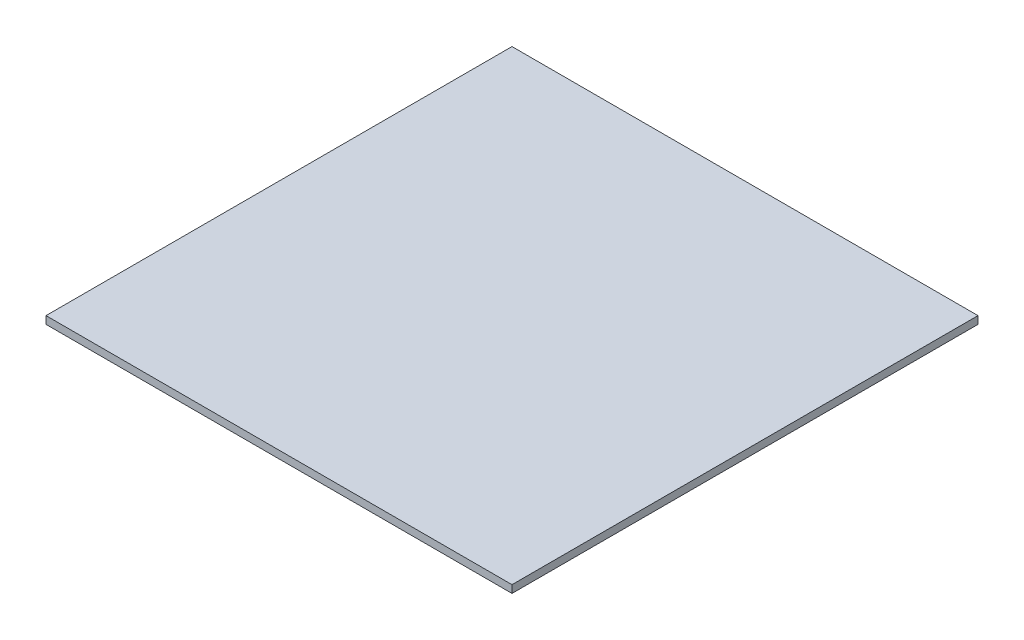
from build123d import *

# Parameters (mm, degrees)
SKETCH1_W           = 381
SKETCH1_H           = 381
BOSS_EXTRUDE1_DEPTH = 6.223


with BuildPart() as part:
    # Sketch1 → Boss-Extrude1 (new body)
    with BuildSketch(Plane(origin=(0, 0, 0), x_dir=(1, 0, 0), z_dir=(0, 1, 0))):
        with Locations((190.5, 190.5)):
            Rectangle(SKETCH1_W, SKETCH1_H)
    extrude(amount=BOSS_EXTRUDE1_DEPTH)


solid = part.part
